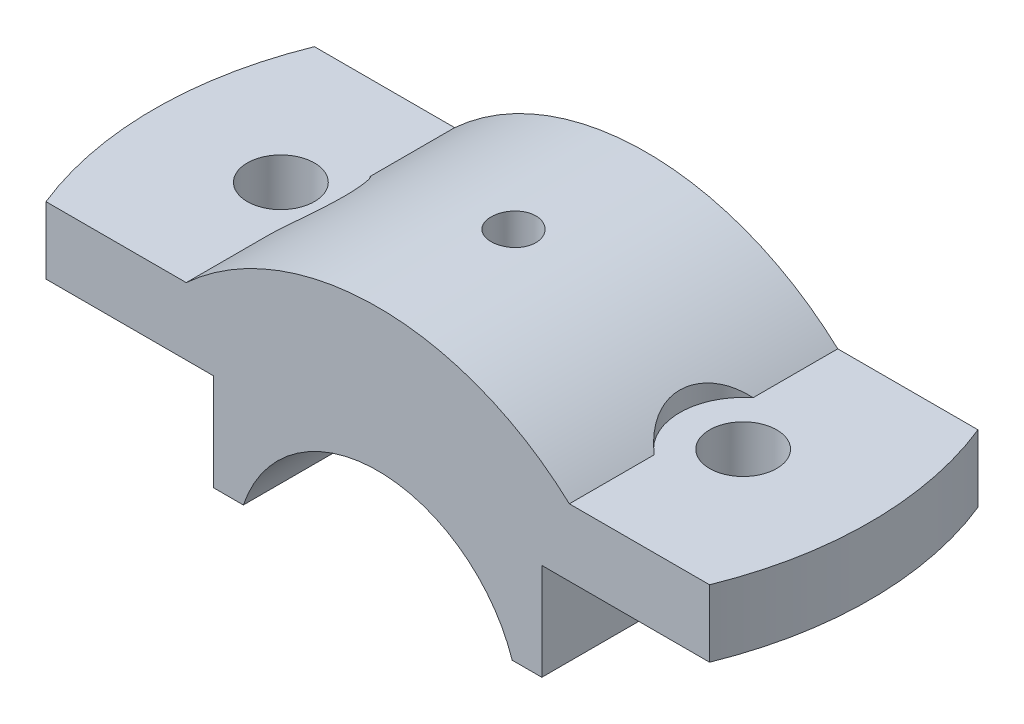
from build123d import *

# Parameters (mm, degrees)
BOSS_EXTRUDE1_DEPTH                     = 18
F_10_0MM_DOWEL_HOLE4_D                  = 9
CBORE_FOR_M5_HEX_HEAD_BOLT1_D           = 5
CBORE_FOR_M5_HEX_HEAD_BOLT1_CBORE_D     = 6
CBORE_FOR_M5_HEX_HEAD_BOLT1_CBORE_DEPTH = 13
CUT_EXTRUDE1_DEPTH                      = 20.0000001
CUT_EXTRUDE7_DEPTH                      = 10


with BuildPart() as part:
    # Sketch1 → Boss-Extrude1 (new body, symmetric)
    with BuildSketch(Plane.XY):
        with BuildLine():
            Line((22, 0), (22, 13))
            Line((22, 13), (50, 13))
            Line((50, 13), (50, 22))
            Line((50, 22), (25.690465157, 22))
            ThreePointArc((25.690465157, 22), (0, 32), (-25.690465157, 22))
            Line((-25.690465157, 22), (-50, 22))
            Line((-50, 22), (-50, 13))
            Line((-50, 13), (-22, 13))
            Line((-22, 13), (-22, 0))
            Line((-22, 0), (-18.027756377, 0))
            ThreePointArc((-18.027756377, 0), (0, 13), (18.027756377, 0))
            Line((18.027756377, 0), (22, 0))
        make_face()
    extrude(amount=BOSS_EXTRUDE1_DEPTH, both=True)

    # Ø10.0mm Dowel Hole4 (through all)
    with Locations(Plane(origin=(0, 22, 0), x_dir=(1, 0, 0), z_dir=(0, 1, 0))):
        with Locations((-31, 0)):
            f_10_0mm_dowel_hole4 = Hole(F_10_0MM_DOWEL_HOLE4_D / 2)

    # Mirror1: Ø10.0mm Dowel Hole4 across plane
    add(f_10_0mm_dowel_hole4.mirror(Plane(origin=(0, 0, 0), x_dir=(0, 0, 1), z_dir=(1, 0, 0))), mode=Mode.SUBTRACT)

    # CBORE for M5 Hex Head Bolt1 (through all)
    with Locations(Plane(origin=(0, 32, -0.198715446), x_dir=(1, 0, 0), z_dir=(0, 1, 0))):
        with Locations((0, 0)):
            CounterBoreHole(CBORE_FOR_M5_HEX_HEAD_BOLT1_D / 2, CBORE_FOR_M5_HEX_HEAD_BOLT1_CBORE_D / 2, CBORE_FOR_M5_HEX_HEAD_BOLT1_CBORE_DEPTH)

    # Sketch14 → Cut-Extrude1 (cut, through all)
    with BuildSketch(Plane.XZ.offset(-13)):
        with BuildLine():
            Line((-44.497190923, 18), (-50, 18))
            Line((-50, 18), (-50, -18))
            Line((-50, -18), (-44.359802254, -18.335974039))
            ThreePointArc((-44.359802254, -18.335974039), (-47.999656889, -0.181489808), (-44.497190923, 18))
        make_face()
        with BuildLine():
            Line((44.497190923, 18), (50, 18))
            Line((50, 18), (50, -18))
            Line((50, -18), (44.497190923, -18))
            ThreePointArc((44.497190923, -18), (48, 0), (44.497190923, 18))
        make_face()
    extrude(amount=-CUT_EXTRUDE1_DEPTH, mode=Mode.SUBTRACT)

    # Sketch17 → Cut-Extrude7 (cut)
    with BuildSketch(Plane(origin=(0, 22, 0), x_dir=(1, 0, 0), z_dir=(0, 1, 0))):
        with BuildLine():
            Line((-25.690465157, -6.637683312), (-25.690465157, 6.637683312))
            ThreePointArc((-25.690465157, 6.637683312), (-22.5, 0), (-25.690465157, -6.637683312))
        make_face()
    cut_extrude7 = extrude(amount=CUT_EXTRUDE7_DEPTH, mode=Mode.SUBTRACT)

    # Mirror3: Cut-Extrude7 across plane
    add(cut_extrude7.mirror(Plane(origin=(0, 0, 0), x_dir=(0, 0, 1), z_dir=(1, 0, 0))), mode=Mode.SUBTRACT)


solid = part.part
